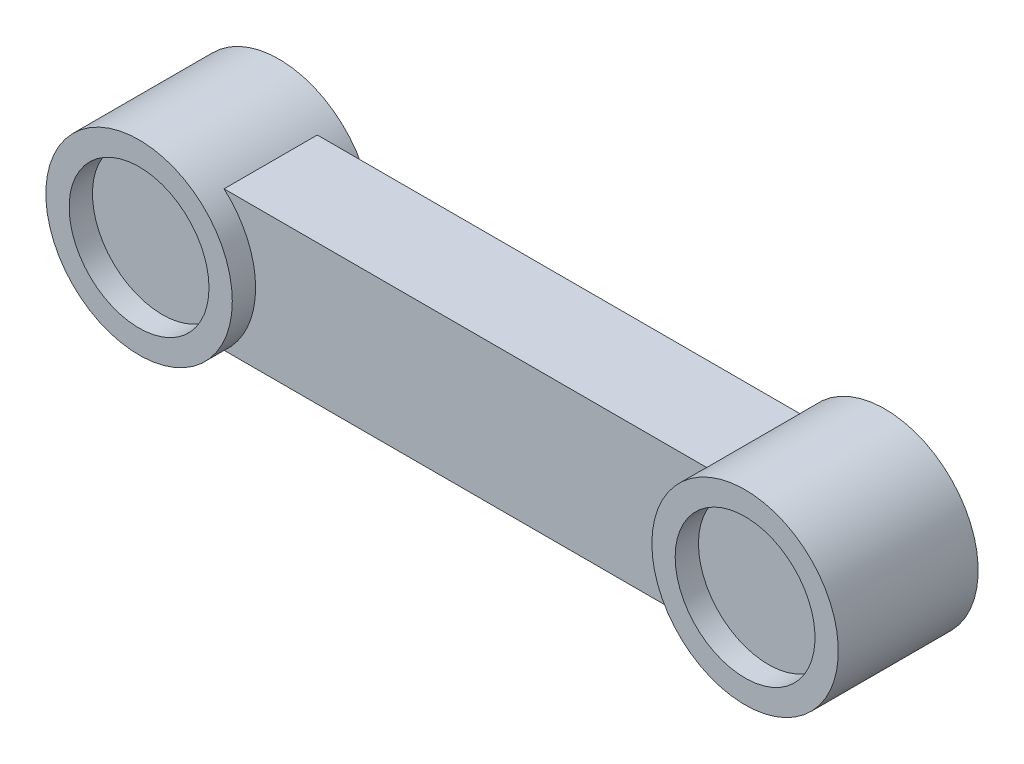
from build123d import *

# Parameters (mm, degrees)
SKETCH1_R             = 40
BOSS_EXTRUDE1_DEPTH   = 60
BOSS_EXTRUDE1_2_DEPTH = 60
BOSS_EXTRUDE3_START   = -3.447986
SKETCH5_W             = 40
SKETCH5_H             = 60
BOSS_EXTRUDE3_DEPTH   = 207.084974
SKETCH3_R             = 6
CUT_EXTRUDE3_DEPTH    = 10
SKETCH4_R             = 6
BOSS_EXTRUDE4_DEPTH   = 10
SKETCH6_R             = 30
CUT_EXTRUDE4_DEPTH    = 10


with BuildPart() as part:
    # Sketch1 → Boss-Extrude1 (new body)
    with BuildSketch(Plane.XY):
        Circle(SKETCH1_R)
    extrude(amount=BOSS_EXTRUDE1_DEPTH)



with BuildPart() as body_2:
    # Sketch1 → Boss-Extrude1 2 (new body)
    with BuildSketch(Plane.XY):
        with Locations((260, 0)):
            Circle(SKETCH1_R)
    extrude(amount=BOSS_EXTRUDE1_2_DEPTH)


with BuildPart() as part_1:
    add(part.part)

    add(body_2.part)  # Boss-Extrude3 merges body 2
    # Sketch5 → Boss-Extrude3 (add)
    with BuildSketch(Plane.ZY.offset(-230.094500915).offset(BOSS_EXTRUDE3_START)):
        with Locations((30, 0)):
            Rectangle(SKETCH5_W, SKETCH5_H)
    extrude(amount=BOSS_EXTRUDE3_DEPTH)

    # Sketch3 → Cut-Extrude3 (cut)
    with BuildSketch(Plane(origin=(0, 0, 0), x_dir=(-1, 0, 0), z_dir=(0, 0, -1))):
        Circle(SKETCH3_R)
    extrude(amount=-CUT_EXTRUDE3_DEPTH, mode=Mode.SUBTRACT)

    # Sketch4 → Boss-Extrude4 (add)
    with BuildSketch(Plane(origin=(0, 0, 0), x_dir=(-1, 0, 0), z_dir=(0, 0, -1))):
        with Locations((-260, 0)):
            Circle(SKETCH4_R)
    extrude(amount=BOSS_EXTRUDE4_DEPTH)

    # Sketch6 → Cut-Extrude4 (cut)
    with BuildSketch(Plane.XY.offset(60)):
        Circle(SKETCH6_R)
        with Locations((260, 0)):
            Circle(SKETCH6_R)
    extrude(amount=-CUT_EXTRUDE4_DEPTH, mode=Mode.SUBTRACT)


solid = part_1.part
